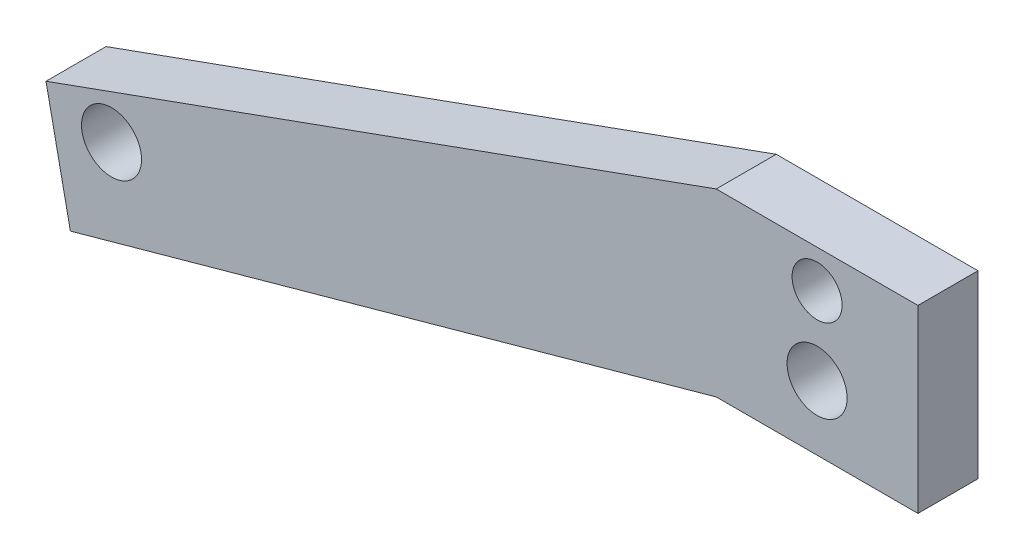
from build123d import *

# Parameters (mm, degrees)
SKETCH1_R           = 3.968749999
SKETCH1_R_2         = 4.762500002
BOSS_EXTRUDE1_DEPTH = 9.525


with BuildPart() as part:
    # Sketch1 → Boss-Extrude1 (new body)
    with BuildSketch(Plane.XY):
        Polygon((-15.999988255, 44.999995413), (-122.310093321, 6.641590837), (-118.444109854, -12.012005917), (-15.999988572, 16.424995395), (16.000011727, 16.424995395), (16.000011745, 44.999995395), align=None)
        with Locations((1.1741e-05, 38.999995404)):
            Circle(SKETCH1_R, mode=Mode.SUBTRACT)
        with Locations((1.1734e-05, 26.647592444)):
            Circle(SKETCH1_R_2, mode=Mode.SUBTRACT)
        with Locations((-111.921568786, 3.451691645)):
            Circle(SKETCH1_R_2, mode=Mode.SUBTRACT)
    extrude(amount=BOSS_EXTRUDE1_DEPTH)


solid = part.part
